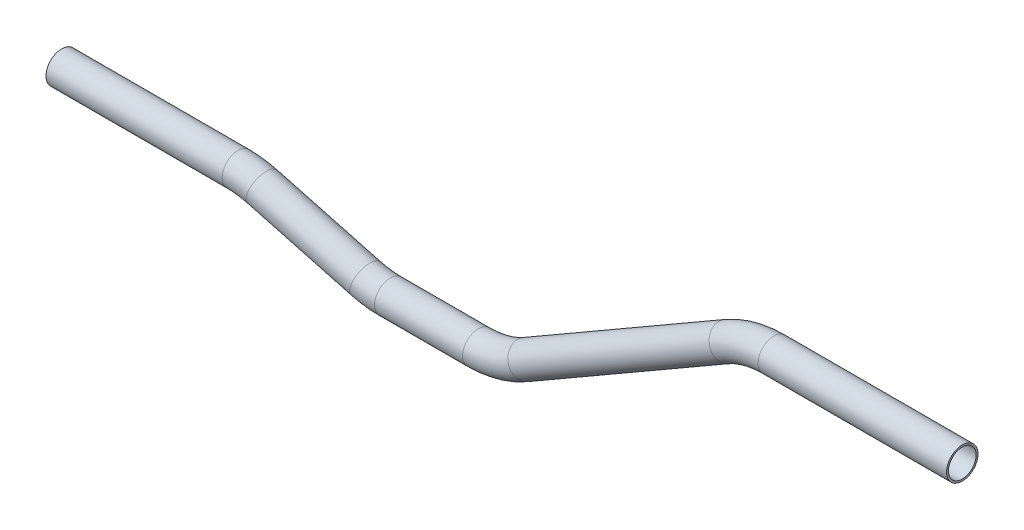
from build123d import *

# Parameters (mm, degrees)
SKETCH2_R   = 6.35
SKETCH2_R_2 = 5.588


with BuildPart() as part:
    # Sweep1: sweep along a path in Sketch1
    with BuildLine(Plane.XY) as sweep1_path:
        Line((-17.584844563, 20.650958781), (53.599195279, 20.650958781))
        ThreePointArc((53.599195279, 20.650958781), (58.572243202, 20.325007999), (63.460200897, 19.352732762))
        Line((63.460200897, 19.352732762), (105.292593551, 8.143776933))
        ThreePointArc((105.292593551, 8.143776933), (110.180551246, 7.171501697), (115.153599169, 6.845550915))
        Line((115.153599169, 6.845550915), (150.72877478, 6.845550915))
        ThreePointArc((150.72877478, 6.845550915), (160.589780398, 8.143776933), (169.77877478, 11.949983031))
        Line((169.77877478, 11.949983031), (251.083206895, 58.891118799))
        ThreePointArc((251.083206895, 58.891118799), (260.272201277, 62.697324897), (270.133206895, 63.995550915))
        Line((270.133206895, 63.995550915), (346.284342664, 63.995550915))
    # Sketch2 → Sweep1 (sweep)
    with BuildSketch(Plane(origin=(-17.584844563, 20.650958781, 0), x_dir=(0, 0, -1), z_dir=(1, 0, 0))):
        Circle(SKETCH2_R)
        Circle(SKETCH2_R_2, mode=Mode.SUBTRACT)
    sweep(path=sweep1_path.line)


solid = part.part
